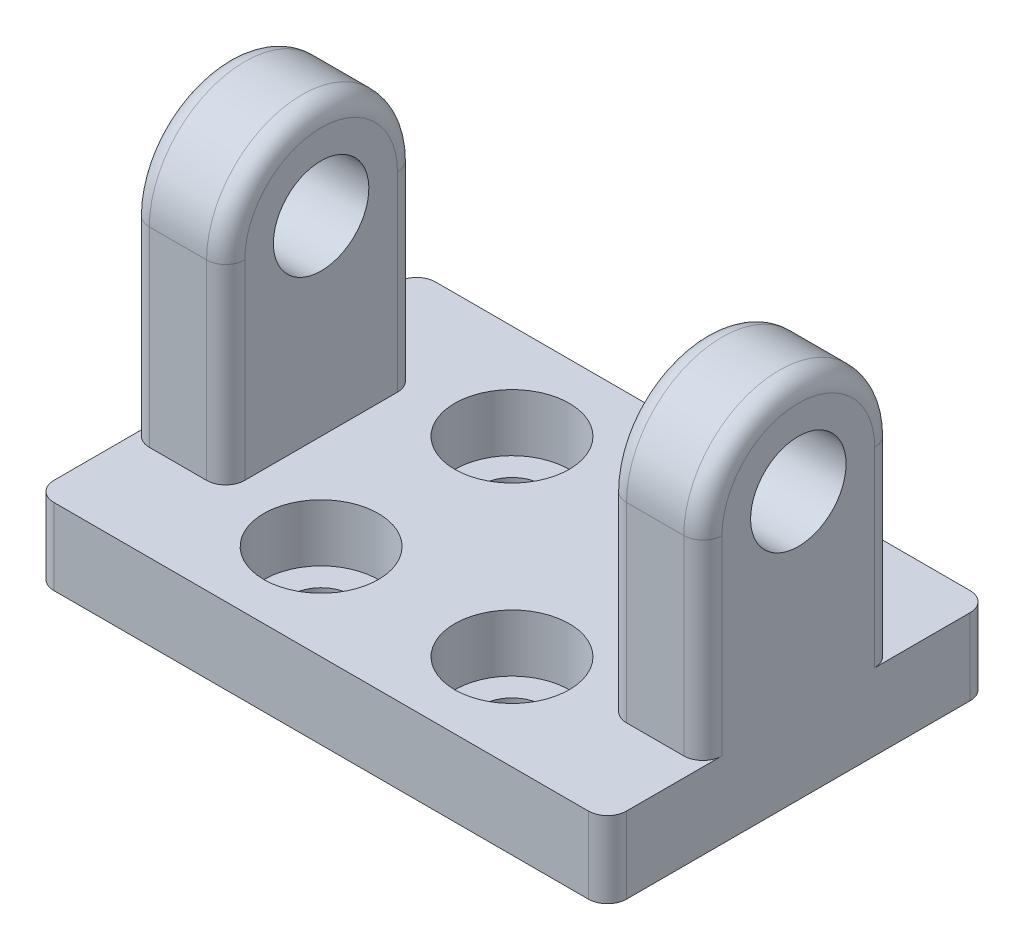
from build123d import *

# Parameters (mm, degrees)
ESQUISSE2_R             = 2.5
BOSS_EXTRU_1_DEPTH      = 15
ESQUISSE4_W             = 30
ESQUISSE4_H             = 20
BOSS_EXTRU_2_DEPTH      = 4
ENL_V_MAT_EXTRU_1_REACH = 6
ESQUISSE5_R             = 1.6
ESQUISSE6_W             = 20
ESQUISSE6_H             = 21.543710407
ENL_V_MAT_EXTRU_2_DEPTH = 16
ESQUISSE7_R             = 3
ENL_V_MAT_EXTRU_3_DEPTH = 3
CONG_1_R                = 1


with BuildPart() as part:
    # Esquisse2 → Boss.-Extru.1 (new body, symmetric)
    with BuildSketch(Plane(origin=(0, 0, 0), x_dir=(0, 0, -1), z_dir=(1, 0, 0))):
        with BuildLine():
            Line((5, 0), (5, -10))
            Line((5, -10), (-5, -10))
            Line((-5, -10), (-5, 0))
            ThreePointArc((-5, 0), (0, 5), (5, 0))
        make_face()
        Circle(ESQUISSE2_R, mode=Mode.SUBTRACT)
    extrude(amount=BOSS_EXTRU_1_DEPTH, both=True)

    # Esquisse4 → Boss.-Extru.2 (add)
    with BuildSketch(Plane.XZ.offset(10)):
        Rectangle(ESQUISSE4_W, ESQUISSE4_H)
    extrude(amount=BOSS_EXTRU_2_DEPTH)

    # Esquisse5 → Enlèv. mat.-Extru.1 (cut, up to next)
    with BuildSketch(Plane(origin=(0, -10, 0), x_dir=(1, 0, 0), z_dir=(0, 1, 0)), mode=Mode.PRIVATE) as enl_v_mat_extru_1_sk1:
        with Locations(Location((5, -5, 0), (0, 0, 270))):  # turned: the seam where the file's is
            Circle(ESQUISSE5_R)
    enl_v_mat_extru_1_tool1 = extrude(enl_v_mat_extru_1_sk1.sketch, amount=-ENL_V_MAT_EXTRU_1_REACH, mode=Mode.PRIVATE) & part.part
    add(enl_v_mat_extru_1_tool1.solids().sort_by_distance((5, -10, 5))[0], mode=Mode.SUBTRACT)
    # Esquisse5 → Enlèv. mat.-Extru.1 (cut, up to next)
    with BuildSketch(Plane(origin=(0, -10, 0), x_dir=(1, 0, 0), z_dir=(0, 1, 0)), mode=Mode.PRIVATE) as enl_v_mat_extru_1_sk2:
        with Locations(Location((5, 5, 0), (0, 0, 270))):  # turned: the seam where the file's is
            Circle(ESQUISSE5_R)
    enl_v_mat_extru_1_tool2 = extrude(enl_v_mat_extru_1_sk2.sketch, amount=-ENL_V_MAT_EXTRU_1_REACH, mode=Mode.PRIVATE) & part.part
    add(enl_v_mat_extru_1_tool2.solids().sort_by_distance((5, -10, -5))[0], mode=Mode.SUBTRACT)
    # Esquisse5 → Enlèv. mat.-Extru.1 (cut, up to next)
    with BuildSketch(Plane(origin=(0, -10, 0), x_dir=(1, 0, 0), z_dir=(0, 1, 0)), mode=Mode.PRIVATE) as enl_v_mat_extru_1_sk3:
        with Locations(Location((-5, 5, 0), (0, 0, 270))):  # turned: the seam where the file's is
            Circle(ESQUISSE5_R)
    enl_v_mat_extru_1_tool3 = extrude(enl_v_mat_extru_1_sk3.sketch, amount=-ENL_V_MAT_EXTRU_1_REACH, mode=Mode.PRIVATE) & part.part
    add(enl_v_mat_extru_1_tool3.solids().sort_by_distance((-5, -10, -5))[0], mode=Mode.SUBTRACT)
    # Esquisse5 → Enlèv. mat.-Extru.1 (cut, up to next)
    with BuildSketch(Plane(origin=(0, -10, 0), x_dir=(1, 0, 0), z_dir=(0, 1, 0)), mode=Mode.PRIVATE) as enl_v_mat_extru_1_sk4:
        with Locations(Location((-5, -5, 0), (0, 0, 270))):  # turned: the seam where the file's is
            Circle(ESQUISSE5_R)
    enl_v_mat_extru_1_tool4 = extrude(enl_v_mat_extru_1_sk4.sketch, amount=-ENL_V_MAT_EXTRU_1_REACH, mode=Mode.PRIVATE) & part.part
    add(enl_v_mat_extru_1_tool4.solids().sort_by_distance((-5, -10, 5))[0], mode=Mode.SUBTRACT)

    # Esquisse6 → Enlèv. mat.-Extru.2 (cut, through all)
    with BuildSketch(Plane.XY.offset(5)):
        with Locations((0, 0.771855204)):
            Rectangle(ESQUISSE6_W, ESQUISSE6_H)
    extrude(amount=-ENL_V_MAT_EXTRU_2_DEPTH, mode=Mode.SUBTRACT)

    # Esquisse7 → Enlèv. mat.-Extru.3 (cut)
    with BuildSketch(Plane(origin=(0, -10, 0), x_dir=(1, 0, 0), z_dir=(0, 1, 0))):
        with Locations(Location((-5, 5, 0), (0, 0, 270))):  # turned: the seam where the file's is
            Circle(ESQUISSE7_R)
        with Locations(Location((5, 5, 0), (0, 0, 270))):  # turned: the seam where the file's is
            Circle(ESQUISSE7_R)
        with Locations(Location((5, -5, 0), (0, 0, 270))):  # turned: the seam where the file's is
            Circle(ESQUISSE7_R)
        with Locations(Location((-5, -5, 0), (0, 0, 270))):  # turned: the seam where the file's is
            Circle(ESQUISSE7_R)
    extrude(amount=-ENL_V_MAT_EXTRU_3_DEPTH, mode=Mode.SUBTRACT)

    # Congé1
    cong_1_edges = [part.edges().sort_by_distance(p)[0] for p in [
        (15, -5, -5),
        (-15, -12, 10),
        (-15, -12, -10),
        (15, -12, -10),
        (15, -12, 10),
        (15, 5, 0),
        (-15, -5, -5),
        (-15, -5, 5),
        (-15, 5, 0),
        (-10, 5, 0),
        (-10, -5, -5),
        (10, -5, -5),
        (10, 5, 0),
        (10, -5, 5),
        (-10, -5, 5),
        (15, -5, 5),
    ]]
    fillet(cong_1_edges, radius=CONG_1_R)


solid = part.part
